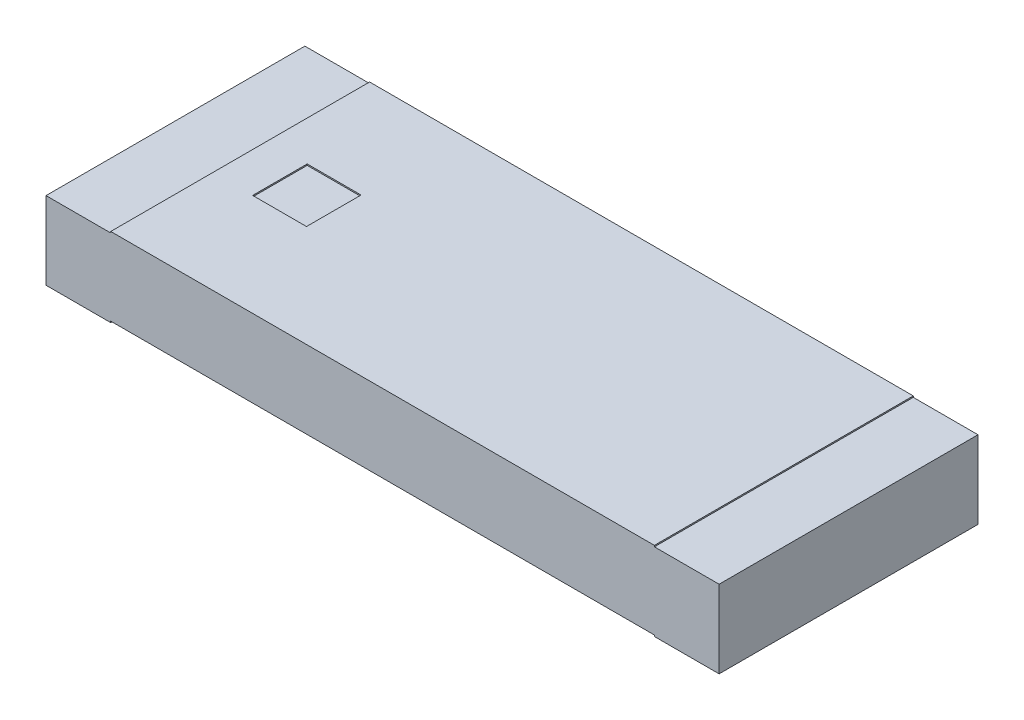
from build123d import *

# Parameters (mm, degrees)
SKETCH_1_W          = 5.2
SKETCH_1_H          = 2
EXTRUDE_1_DEPTH     = 0.6
SKETCH_2_W          = 4.2
SKETCH_2_H          = 2
EXTRUDE_2_DEPTH     = 0.01
SKETCH_3_W          = 0.416220045
SKETCH_3_H          = 0.4215562
CUT_EXTRUDE_1_DEPTH = 0.01
SKETCH_4_W          = 4.2
SKETCH_4_H          = 2
CUT_EXTRUDE_2_DEPTH = 0.01


with BuildPart() as part:
    # Эскиз1 → Бобышка-Вытянуть1 (new body)
    with BuildSketch(Plane(origin=(0, 0, 0), x_dir=(1, 0, 0), z_dir=(0, 1, 0))):
        Rectangle(SKETCH_1_W, SKETCH_1_H)
    extrude(amount=EXTRUDE_1_DEPTH)

    # Эскиз2 → Бобышка-Вытянуть2 (add)
    with BuildSketch(Plane(origin=(0, 0.6, 0), x_dir=(1, 0, 0), z_dir=(0, 1, 0))):
        Rectangle(SKETCH_2_W, SKETCH_2_H)
    extrude(amount=EXTRUDE_2_DEPTH)

    # Эскиз3 → Вырез-Вытянуть1 (cut)
    with BuildSketch(Plane(origin=(0, 0.61, 0), x_dir=(1, 0, 0), z_dir=(0, 1, 0))):
        with Locations((-1.584837867, 0)):
            Rectangle(SKETCH_3_W, SKETCH_3_H)
    extrude(amount=-CUT_EXTRUDE_1_DEPTH, mode=Mode.SUBTRACT)

    # Эскиз4 → Вырез-Вытянуть2 (cut)
    with BuildSketch(Plane.XZ):
        Rectangle(SKETCH_4_W, SKETCH_4_H)
    extrude(amount=-CUT_EXTRUDE_2_DEPTH, mode=Mode.SUBTRACT)


solid = part.part
